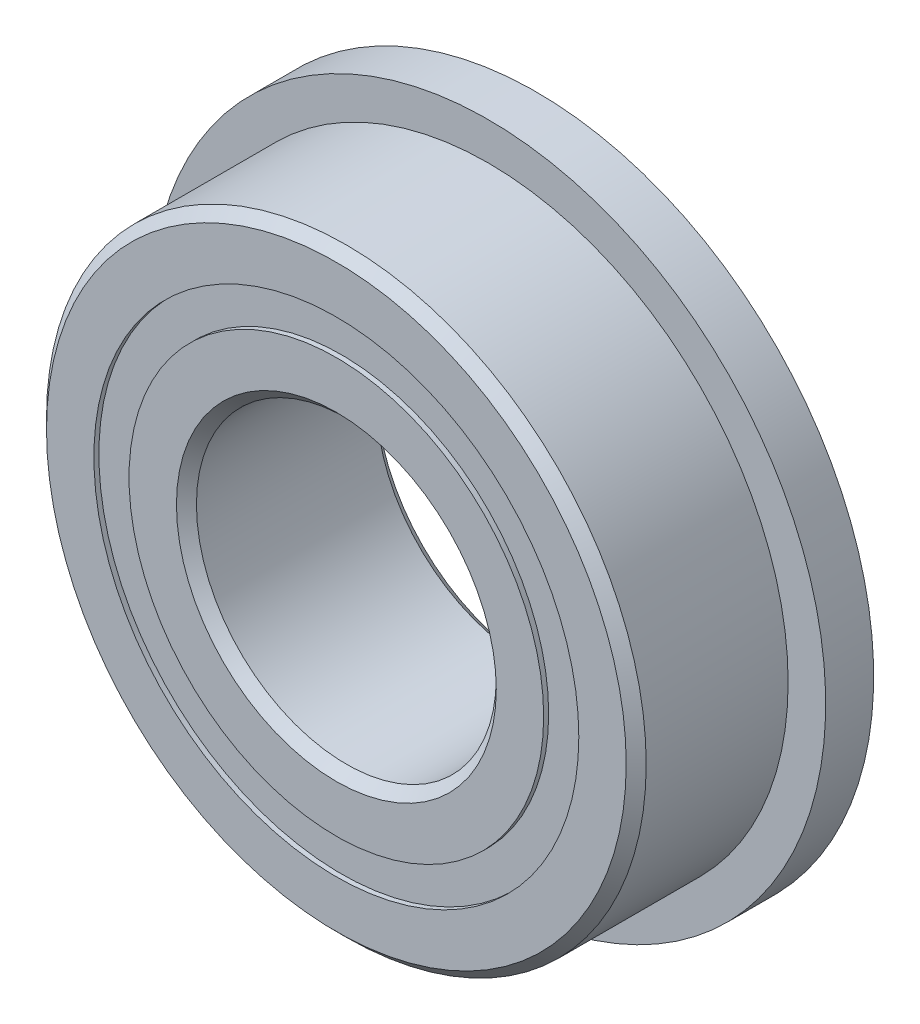
from build123d import *

# Parameters (mm, degrees)
CIRPATTERN1_COUNT = 12
SKETCH5_W         = 0.749364756
SKETCH5_H         = 0.558241758
SKETCH6_W         = 0.762
SKETCH6_H         = 1.508404121


with BuildPart() as part:
    # Sketch → Revolve1 (revolve)
    with BuildSketch(Plane(origin=(0, 0, 0), x_dir=(0, 0, -1), z_dir=(1, 0, 0))):
        with BuildLine():
            Line((1.42875, 4.7625), (-1.42875, 4.7625))
            Line((-1.42875, 4.7625), (-1.5875, 4.60375))
            Line((-1.5875, 4.60375), (-1.5875, 3.850995879))
            Line((-1.5875, 3.850995879), (-0.705555556, 3.850995879))
            ThreePointArc((-0.705555556, 3.850995879), (0, 4.330635244), (0.705555556, 3.850995879))
            Line((0.705555556, 3.850995879), (1.5875, 3.850995879))
            Line((1.5875, 3.850995879), (1.5875, 4.60375))
            Line((1.5875, 4.60375), (1.42875, 4.7625))
        make_face()
    revolve(axis=Axis((0, 0, 1.5875), (0, 0, -1)))

    # Sketch6 → Revolve6 (revolve)
    with BuildSketch(Plane(origin=(0, 0, 0), x_dir=(0, 0, -1), z_dir=(1, 0, 0))):
        with Locations((1.2065, 4.60519794)):
            Rectangle(SKETCH6_W, SKETCH6_H)
    revolve(axis=Axis((0, 0, -1.5875), (0, 0, 1)))


with BuildPart() as body_2:
    # Sketch3 → Revolve3 (revolve)
    with BuildSketch(Plane(origin=(0, 0, 0), x_dir=(0, 0, -1), z_dir=(1, 0, 0))):
        with BuildLine():
            Line((-1.5875, 3.292754121), (-0.705555556, 3.292754121))
            ThreePointArc((-0.705555556, 3.292754121), (0, 2.813114756), (0.705555556, 3.292754121))
            Line((0.705555556, 3.292754121), (1.5875, 3.292754121))
            Line((1.5875, 3.292754121), (1.5875, 2.54))
            Line((1.5875, 2.54), (1.42875, 2.38125))
            Line((1.42875, 2.38125), (-1.42875, 2.38125))
            Line((-1.42875, 2.38125), (-1.5875, 2.54))
            Line((-1.5875, 2.54), (-1.5875, 3.292754121))
        make_face()
    revolve(axis=Axis((0, 0, 1.5875), (0, 0, -1)))


with BuildPart() as body_3:
    # Sketch4 → Revolve4 (revolve)
    with BuildSketch(Plane(origin=(0, 0, 0), x_dir=(0, 0, -1), z_dir=(1, 0, 0))):
        with BuildLine():
            Line((-0.758760244, 3.571875), (0.758760244, 3.571875))
            ThreePointArc((0.758760244, 3.571875), (0, 4.330635244), (-0.758760244, 3.571875))
        make_face()
    revolve(axis=Axis((0, 3.571875, 0.758760244), (0, 0, -1)))


with BuildPart() as cirpattern1_1:
    # CirPattern1: pattern copy
    add(body_3.part.rotate(Axis((0, 0, -1.5875), (0, 0, 1)), 1 * 360 / CIRPATTERN1_COUNT))


with BuildPart() as cirpattern1_2:
    # CirPattern1: pattern copy
    add(body_3.part.rotate(Axis((0, 0, -1.5875), (0, 0, 1)), 2 * 360 / CIRPATTERN1_COUNT))


with BuildPart() as cirpattern1_3:
    # CirPattern1: pattern copy
    add(body_3.part.rotate(Axis((0, 0, -1.5875), (0, 0, 1)), 3 * 360 / CIRPATTERN1_COUNT))


with BuildPart() as cirpattern1_4:
    # CirPattern1: pattern copy
    add(body_3.part.rotate(Axis((0, 0, -1.5875), (0, 0, 1)), 4 * 360 / CIRPATTERN1_COUNT))


with BuildPart() as cirpattern1_5:
    # CirPattern1: pattern copy
    add(body_3.part.rotate(Axis((0, 0, -1.5875), (0, 0, 1)), 5 * 360 / CIRPATTERN1_COUNT))


with BuildPart() as cirpattern1_6:
    # CirPattern1: pattern copy
    add(body_3.part.rotate(Axis((0, 0, -1.5875), (0, 0, 1)), 6 * 360 / CIRPATTERN1_COUNT))


with BuildPart() as cirpattern1_7:
    # CirPattern1: pattern copy
    add(body_3.part.rotate(Axis((0, 0, -1.5875), (0, 0, 1)), 7 * 360 / CIRPATTERN1_COUNT))


with BuildPart() as cirpattern1_8:
    # CirPattern1: pattern copy
    add(body_3.part.rotate(Axis((0, 0, -1.5875), (0, 0, 1)), 8 * 360 / CIRPATTERN1_COUNT))


with BuildPart() as cirpattern1_9:
    # CirPattern1: pattern copy
    add(body_3.part.rotate(Axis((0, 0, -1.5875), (0, 0, 1)), 9 * 360 / CIRPATTERN1_COUNT))


with BuildPart() as cirpattern1_10:
    # CirPattern1: pattern copy
    add(body_3.part.rotate(Axis((0, 0, -1.5875), (0, 0, 1)), 10 * 360 / CIRPATTERN1_COUNT))


with BuildPart() as cirpattern1_11:
    # CirPattern1: pattern copy
    add(body_3.part.rotate(Axis((0, 0, -1.5875), (0, 0, 1)), 11 * 360 / CIRPATTERN1_COUNT))


with BuildPart() as body_15:
    # Sketch5 → Revolve5 (revolve)
    with BuildSketch(Plane(origin=(0, 0, 0), x_dir=(0, 0, -1), z_dir=(1, 0, 0))):
        with Locations((-1.133442622, 3.571875)):
            Rectangle(SKETCH5_W, SKETCH5_H)
        with Locations((1.133442622, 3.571875)):
            Rectangle(SKETCH5_W, SKETCH5_H)
    revolve(axis=Axis((0, 0, 1.5875), (0, 0, -1)))


solid = Compound([part.part, body_2.part, body_3.part, cirpattern1_1.part, cirpattern1_2.part, cirpattern1_3.part, cirpattern1_4.part, cirpattern1_5.part, cirpattern1_6.part, cirpattern1_7.part, cirpattern1_8.part, cirpattern1_9.part, cirpattern1_10.part, cirpattern1_11.part, body_15.part])
